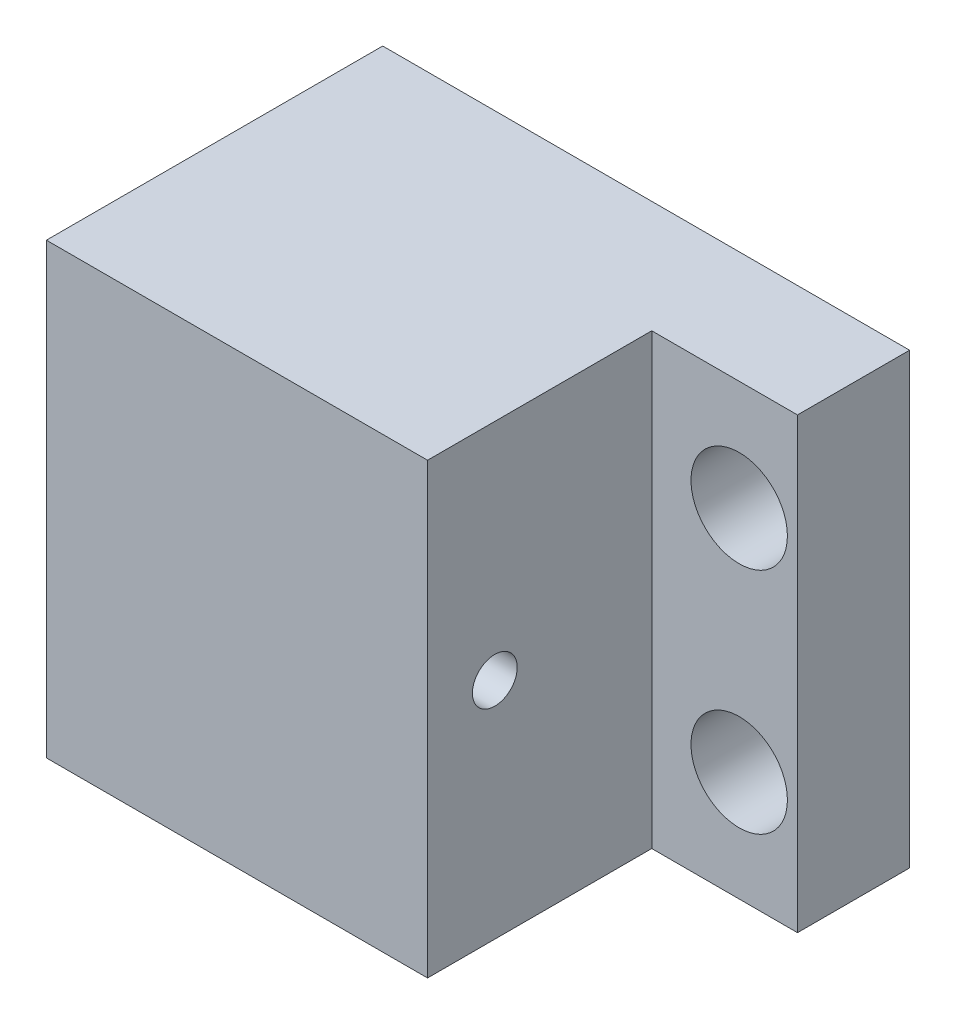
from build123d import *

# Parameters (mm, degrees)
BOSS_EXTRUDE1_DEPTH = 5
SKETCH2_W           = 17
SKETCH2_H           = 20
BOSS_EXTRUDE2_DEPTH = 10
SKETCH3_R           = 1
CUT_EXTRUDE1_DEPTH  = 18
SKETCH4_R           = 2.15
CUT_EXTRUDE2_DEPTH  = 6


with BuildPart() as part:
    # Sketch1 → Boss-Extrude1 (new body)
    with BuildSketch(Plane.XY):
        Polygon((-12.102505447, 7.889651416), (11.397494553, 7.889651416), (11.397494553, 27.889651416), (-12.102505447, 27.889651416), (-12.102505447, 26.889651416), (-0.102505447, 26.889651416), (-0.102505447, 22.98867093), (1.897494553, 22.98867093), (1.897494553, 12.790631903), (-0.102505447, 12.790631903), (-0.102505447, 8.889651416), (-1.102505447, 8.889651416), (-12.102505447, 8.889651416), align=None)
    extrude(amount=BOSS_EXTRUDE1_DEPTH)

    # Sketch2 → Boss-Extrude2 (add)
    with BuildSketch(Plane.XY.offset(5)):
        with Locations((-3.602505447, 17.889651416)):
            Rectangle(SKETCH2_W, SKETCH2_H)
    extrude(amount=BOSS_EXTRUDE2_DEPTH)

    # Sketch3 → Cut-Extrude1 (cut, through all)
    with BuildSketch(Plane(origin=(4.897494553, 0, 0), x_dir=(0, 0, -1), z_dir=(1, 0, 0))):
        with Locations((-12, 17.889651416)):
            Circle(SKETCH3_R)
    extrude(amount=-CUT_EXTRUDE1_DEPTH, mode=Mode.SUBTRACT)

    # Sketch4 → Cut-Extrude2 (cut, through all)
    with BuildSketch(Plane.XY.offset(5)):
        with Locations((8.797494553, 12.789651416)):
            Circle(SKETCH4_R)
        with Locations((8.797494553, 22.989651416)):
            Circle(SKETCH4_R)
    extrude(amount=-CUT_EXTRUDE2_DEPTH, mode=Mode.SUBTRACT)


solid = part.part
